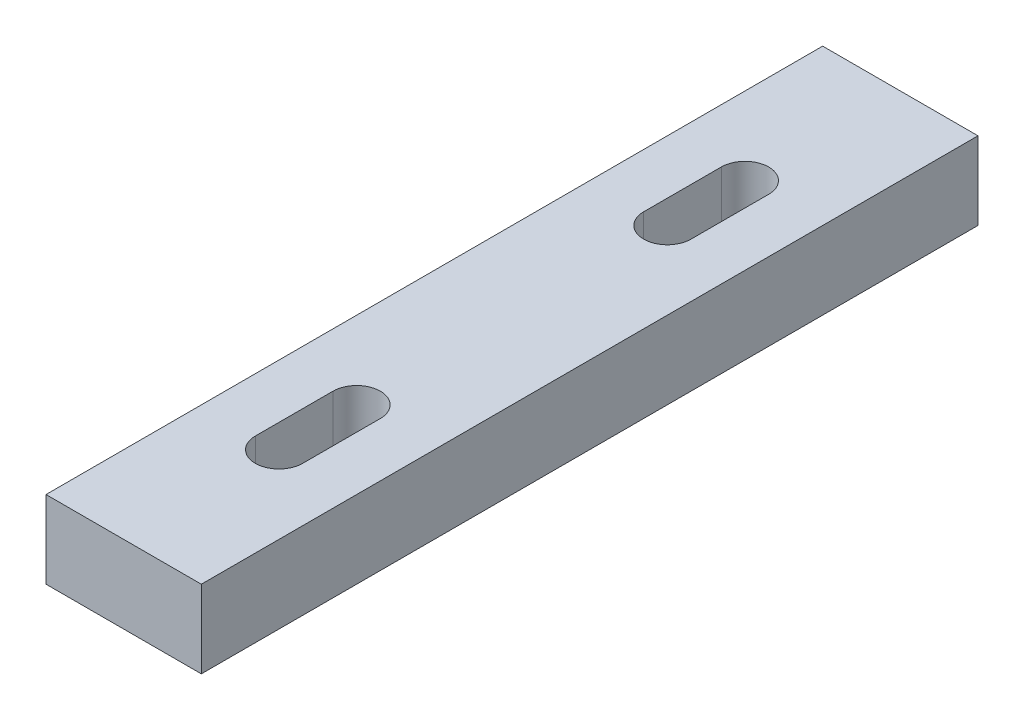
from build123d import *

# Parameters (mm, degrees)
SKETCH1_W           = 20
SKETCH1_H           = 100
BOSS_EXTRUDE1_DEPTH = 10
CUT_EXTRUDE1_DEPTH  = 10


with BuildPart() as part:
    # Sketch1 → Boss-Extrude1 (new body)
    with BuildSketch(Plane(origin=(0, 0, 0), x_dir=(1, 0, 0), z_dir=(0, 1, 0))):
        Rectangle(SKETCH1_W, SKETCH1_H)
    extrude(amount=BOSS_EXTRUDE1_DEPTH)

    # Sketch2 → Cut-Extrude1 (cut)
    with BuildSketch(Plane(origin=(0, 10, 0), x_dir=(1, 0, 0), z_dir=(0, 1, 0))):
        with BuildLine():
            Line((3.05, 30), (3.05, 20))
            ThreePointArc((3.05, 20), (0, 16.95), (-3.05, 20))
            Line((-3.05, 20), (-3.05, 30))
            ThreePointArc((-3.05, 30), (0, 33.05), (3.05, 30))
        make_face()
    cut_extrude1 = extrude(amount=-CUT_EXTRUDE1_DEPTH, mode=Mode.SUBTRACT)

    # Mirror1: Cut-Extrude1 across plane
    add(cut_extrude1.mirror(Plane.XY), mode=Mode.SUBTRACT)


solid = part.part
